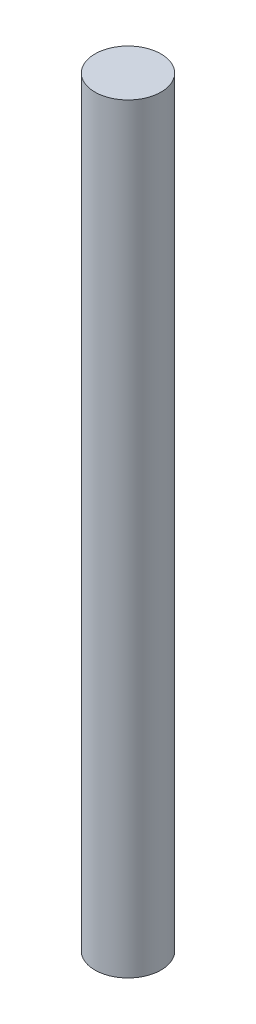
from build123d import *

# Parameters (mm, degrees)
SKETCH1_R           = 1
BOSS_EXTRUDE1_DEPTH = 23


with BuildPart() as part:
    # Sketch1 → Boss-Extrude1 (new body)
    with BuildSketch(Plane(origin=(0, 0, 0), x_dir=(1, 0, 0), z_dir=(0, 1, 0))):
        Circle(SKETCH1_R)
    extrude(amount=BOSS_EXTRUDE1_DEPTH)


solid = part.part
